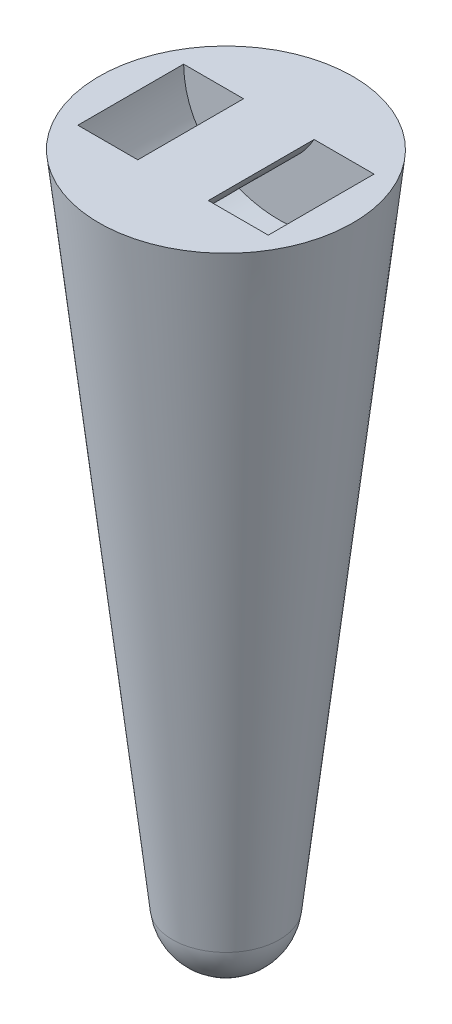
from build123d import *

# Parameters (mm, degrees)
ENL_V_MAT_EXTRU_1_DEPTH      = 7.5
ENL_V_MAT_EXTRU_1_DEPTH_BACK = 7.5
BOSS_EXTRU_1_REACH           = 27.5
ECHELLE1_SCALE               = 1.6


with BuildPart() as part:
    # Esquisse1 → R_volution1 (revolve)
    with BuildSketch(Plane.XY):
        with BuildLine():
            Line((0, 0), (0, 100))
            Line((0, 100), (-18, 100))
            Line((-18, 100), (-7.593007693, 6.792401612))
            ThreePointArc((-7.593007693, 6.792401612), (-5.093880777, 1.945904787), (0, 0))
        make_face()
    revolve(axis=Axis((0, 0, 0), (0, 1, 0)))

    # Esquisse2 → Enl_v. mat.-Extru.1 (cut, two sides)
    with BuildSketch(Plane.XY) as enl_v_mat_extru_1_sk:
        with BuildLine():
            Line((-13.5, 100), (13.5, 100))
            add(Edge.make_bspline(
                [(-13.5, 100), (-13.291113541, 83.520875666), (13.291113541, 83.520875666), (13.5, 100)],
                knots=[0, 0, 0, 0, 1, 1, 1, 1], degree=3))
        make_face()
    extrude(amount=ENL_V_MAT_EXTRU_1_DEPTH, mode=Mode.SUBTRACT)
    extrude(enl_v_mat_extru_1_sk.sketch, amount=-ENL_V_MAT_EXTRU_1_DEPTH_BACK, mode=Mode.SUBTRACT)

    # Esquisse3 → Boss.-Extru.1 (add, up to next)
    with BuildSketch(Plane.XY.offset(-7.5), mode=Mode.PRIVATE) as boss_extru_1_sk1:
        with BuildLine():
            Line((-5, 100), (5, 100))
            add(Edge.make_bspline(
                [(-5, 100), (0, 91.498247822), (5, 100)],
                knots=[0, 0, 0, 1, 1, 1], degree=2))
        make_face()
    boss_extru_1_tool1 = extrude(boss_extru_1_sk1.sketch, amount=BOSS_EXTRU_1_REACH, mode=Mode.PRIVATE) - part.part
    add(boss_extru_1_tool1.solids().sort_by_distance((0, 98.29965, -7.5))[0])


with BuildPart() as part_1:
    # Echelle1: scaled about (-4e-09, 62.219241992, 3e-09)
    add(part.part.scale(ECHELLE1_SCALE).moved(Location((2e-09, -37.331545195, -2e-09))))


solid = part_1.part
